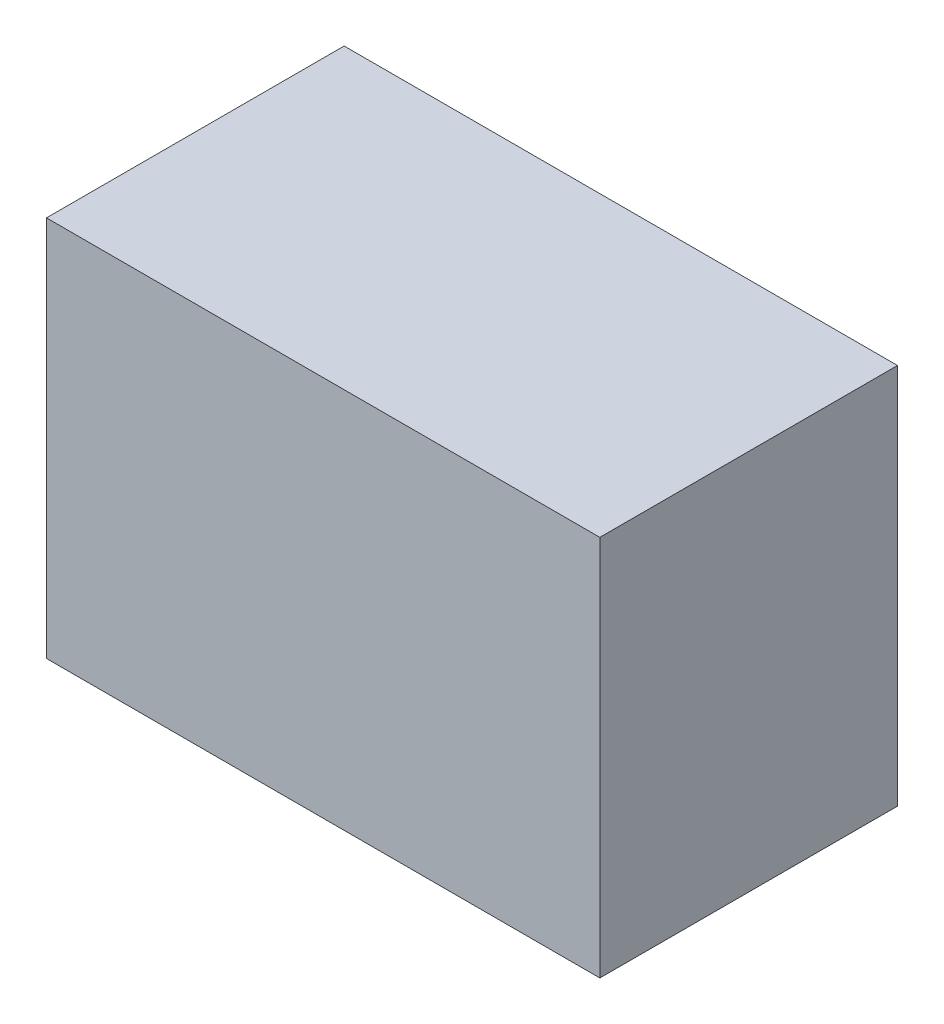
from build123d import *

# Parameters (mm, degrees)
SKETCH1_W           = 145
SKETCH1_H           = 100
BOSS_EXTRUDE1_DEPTH = 78


with BuildPart() as part:
    # Sketch1 → Boss-Extrude1 (new body)
    with BuildSketch(Plane.XY):
        with Locations((527.5, 22.5)):
            Rectangle(SKETCH1_W, SKETCH1_H)
    extrude(amount=BOSS_EXTRUDE1_DEPTH)


solid = part.part
